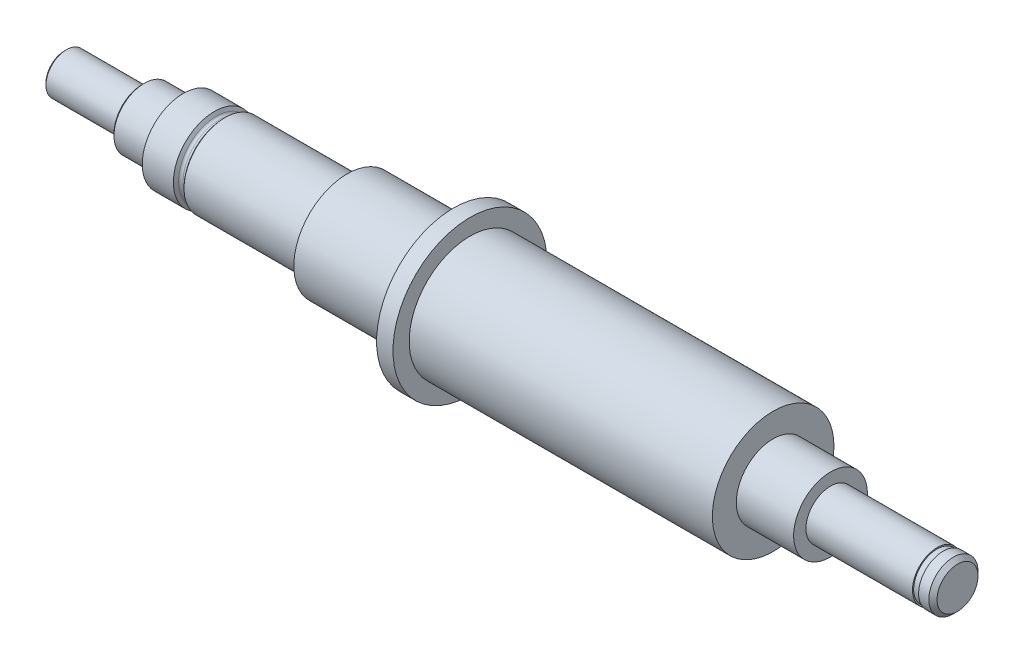
from build123d import *

# Parameters (mm, degrees)
M3_TAPPED_HOLE1_D           = 2.5
M3_TAPPED_HOLE1_DEPTH       = 8.5
M3_TAPPED_HOLE1_CSINK_D     = 3.05
M3_TAPPED_HOLE1_CSINK_ANGLE = 120
M3_TAPPED_HOLE1_TIP         = 0.751075774


with BuildPart() as part:
    # Sketch1 → Revolve3 (revolve)
    with BuildSketch(Plane.XY):
        with BuildLine():
            Line((-35, 5), (-31.2, 5))
            Line((-31.2, 5), (-30.969059892, 4.6))
            ThreePointArc((-30.969059892, 4.6), (-30.822649731, 4.453589838), (-30.622649731, 4.4))
            Line((-30.622649731, 4.4), (-30.4, 4.4))
            ThreePointArc((-30.4, 4.4), (-30.117157288, 4.517157288), (-30, 4.8))
            Line((-30, 4.8), (-30, 4.9))
            Line((-30, 4.9), (-29.9, 5))
            Line((-29.9, 5), (-15, 5))
            Line((-15, 5), (-15, 6.5))
            Line((-15, 6.5), (-2, 6.5))
            Line((-2, 6.5), (-2, 9.4))
            Line((-2, 9.4), (0, 9.4))
            Line((0, 9.4), (0, 7.42))
            Line((0, 7.42), (37, 7.42))
            Line((37, 7.42), (37, 4.5))
            Line((37, 4.5), (44, 4.5))
            Line((44, 4.5), (44, 3))
            Line((44, 3), (57, 3))
            Line((57, 3), (57, 2.85))
            Line((57, 2.85), (57.75, 2.85))
            Line((57.75, 2.85), (57.75, 3))
            Line((57.75, 3), (59, 3))
            Line((59, 3), (59.5, 2.5))
            Line((59.5, 2.5), (59.5, 0))
            Line((59.5, 0), (-49.5, 0))
            Line((-49.5, 0), (-49.5, 2.25))
            Line((-49.5, 2.25), (-49.25, 2.5))
            Line((-49.25, 2.5), (-40, 2.5))
            Line((-40, 2.5), (-40, 3.45))
            Line((-40, 3.45), (-39.75, 3.7))
            Line((-39.75, 3.7), (-35.683012702, 3.7))
            ThreePointArc((-35.683012702, 3.7), (-35.506236007, 3.773223305), (-35.433012702, 3.95))
            Line((-35.433012702, 3.95), (-35.433012702, 4.25))
            Line((-35.433012702, 4.25), (-35, 5))
        make_face()
    revolve(axis=Axis((88.99, 0, 0), (-1, 0, 0)))

    # M3 Tapped Hole1
    with Locations(Plane.ZY.offset(49.5)):
        with Locations((0, 0)):
            CounterSinkHole(M3_TAPPED_HOLE1_D / 2, M3_TAPPED_HOLE1_CSINK_D / 2, depth=M3_TAPPED_HOLE1_DEPTH, counter_sink_angle=M3_TAPPED_HOLE1_CSINK_ANGLE)
            with Locations((0, 0, -(M3_TAPPED_HOLE1_DEPTH + M3_TAPPED_HOLE1_TIP / 2))):  # 118° drill point
                Cone(0, M3_TAPPED_HOLE1_D / 2, M3_TAPPED_HOLE1_TIP, mode=Mode.SUBTRACT)


solid = part.part
